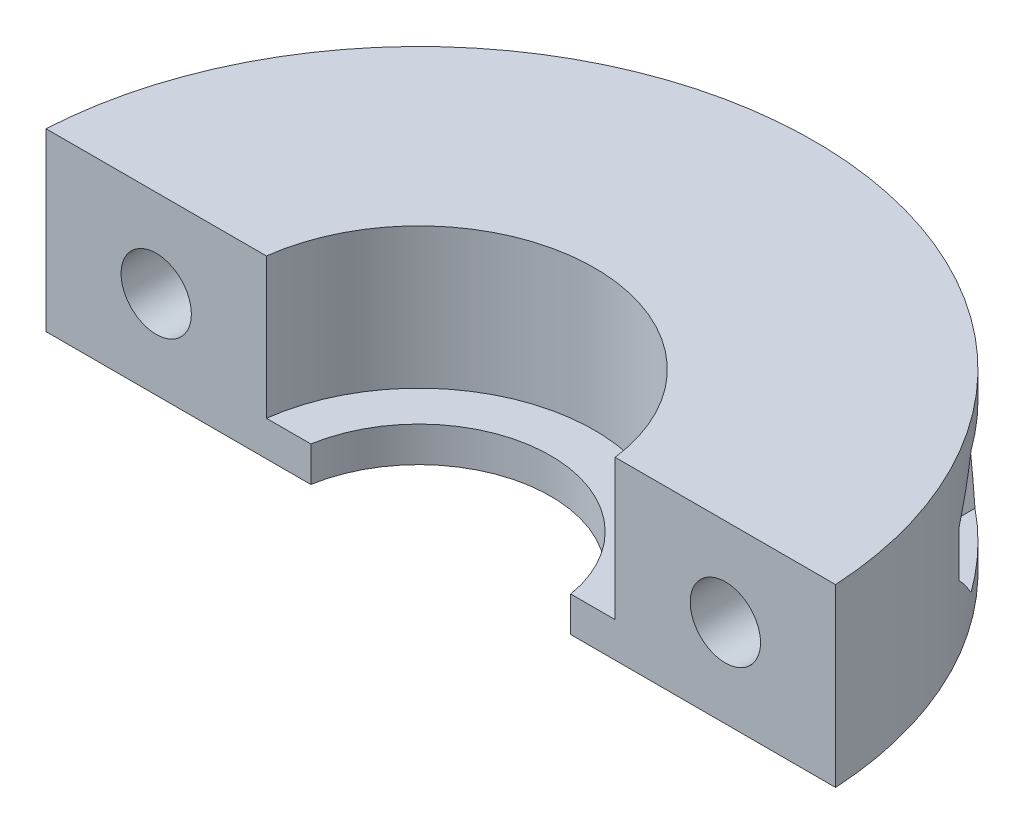
from build123d import *

# Parameters (mm, degrees)
SKETCH1_R           = 18
SKETCH1_R_2         = 8
BOSS_EXTRUDE1_DEPTH = 8
SKETCH2_R           = 8
SKETCH2_R_2         = 6
BOSS_EXTRUDE2_DEPTH = 1.6
SKETCH3_W           = 40
SKETCH3_H           = 20
CUT_EXTRUDE1_DEPTH  = 9
CUT_EXTRUDE2_REACH  = 19
SKETCH5_R           = 1.6
CUT_EXTRUDE3_REACH  = 27
CUT_EXTRUDE3_START  = -8


with BuildPart() as part:
    # Sketch1 → Boss-Extrude1 (new body)
    with BuildSketch(Plane(origin=(0, 0, 0), x_dir=(1, 0, 0), z_dir=(0, 1, 0))):
        Circle(SKETCH1_R)
        Circle(SKETCH1_R_2, mode=Mode.SUBTRACT)
    extrude(amount=BOSS_EXTRUDE1_DEPTH)

    # Sketch2 → Boss-Extrude2 (add)
    with BuildSketch(Plane(origin=(0, 0, 0), x_dir=(1, 0, 0), z_dir=(0, 1, 0))):
        Circle(SKETCH2_R)
        Circle(SKETCH2_R_2, mode=Mode.SUBTRACT)
    extrude(amount=BOSS_EXTRUDE2_DEPTH)

    # Sketch3 → Cut-Extrude1 (cut, through all)
    with BuildSketch(Plane(origin=(0, 8, 0), x_dir=(1, 0, 0), z_dir=(0, 1, 0))):
        with Locations((0, -9)):
            Rectangle(SKETCH3_W, SKETCH3_H)
    extrude(amount=-CUT_EXTRUDE1_DEPTH, mode=Mode.SUBTRACT)

    # Sketch5 → Cut-Extrude2 (cut, up to next)
    with BuildSketch(Plane.XY.offset(-1), mode=Mode.PRIVATE) as cut_extrude2_sk1:
        with Locations((-12.954727344, 4)):
            Circle(SKETCH5_R)
    cut_extrude2_tool1 = extrude(cut_extrude2_sk1.sketch, amount=-CUT_EXTRUDE2_REACH, mode=Mode.PRIVATE) & part.part
    add(cut_extrude2_tool1.solids().sort_by_distance((-12.954727, 4, -1))[0], mode=Mode.SUBTRACT)
    # Sketch5 → Cut-Extrude2 (cut, up to next)
    with BuildSketch(Plane.XY.offset(-1), mode=Mode.PRIVATE) as cut_extrude2_sk2:
        with Locations((12.954727344, 4)):
            Circle(SKETCH5_R)
    cut_extrude2_tool2 = extrude(cut_extrude2_sk2.sketch, amount=-CUT_EXTRUDE2_REACH, mode=Mode.PRIVATE) & part.part
    add(cut_extrude2_tool2.solids().sort_by_distance((12.954727, 4, -1))[0], mode=Mode.SUBTRACT)

    # Sketch6 → Cut-Extrude3 (cut, up to next)
    with BuildSketch(Plane.XY.offset(-1).offset(CUT_EXTRUDE3_START), mode=Mode.PRIVATE) as cut_extrude3_sk1:
        Polygon((-9.721565837, 4), (-11.338146591, 6.8), (-14.571308098, 6.8), (-16.187888852, 4), (-14.571308098, 1.2), (-11.338146591, 1.2), align=None)
    cut_extrude3_tool1 = extrude(cut_extrude3_sk1.sketch, amount=-CUT_EXTRUDE3_REACH, mode=Mode.PRIVATE) & part.part
    add(cut_extrude3_tool1.solids().sort_by_distance((-12.954727, 4, -9))[0], mode=Mode.SUBTRACT)
    # Sketch6 → Cut-Extrude3 (cut, up to next)
    with BuildSketch(Plane.XY.offset(-1).offset(CUT_EXTRUDE3_START), mode=Mode.PRIVATE) as cut_extrude3_sk2:
        Polygon((16.187888852, 4), (14.571308098, 6.8), (11.338146591, 6.8), (9.721565837, 4), (11.338146591, 1.2), (14.571308098, 1.2), align=None)
    cut_extrude3_tool2 = extrude(cut_extrude3_sk2.sketch, amount=-CUT_EXTRUDE3_REACH, mode=Mode.PRIVATE) & part.part
    add(cut_extrude3_tool2.solids().sort_by_distance((12.954727, 4, -9))[0], mode=Mode.SUBTRACT)


solid = part.part
